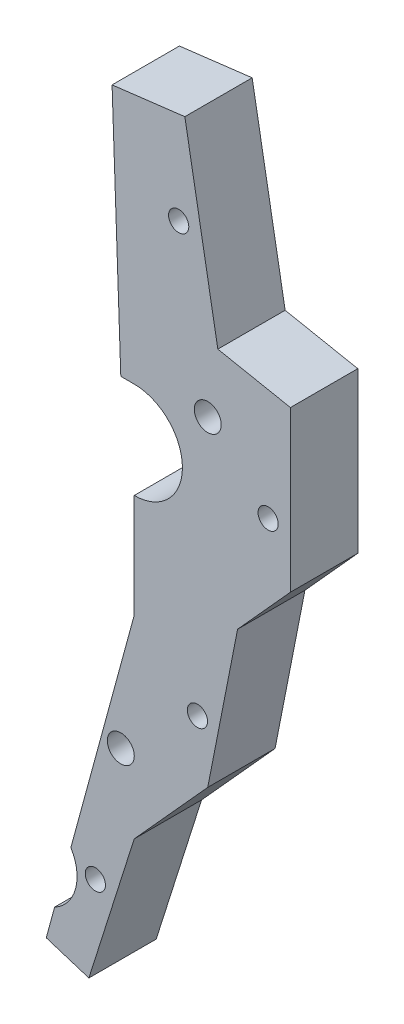
from build123d import *

# Parameters (mm, degrees)
SKETCH1_R           = 0.75
SKETCH1_R_2         = 1
BOSS_EXTRUDE1_DEPTH = 5
SKETCH2_R           = 3.161990297
CUT_EXTRUDE3_DEPTH  = 6


with BuildPart() as part:
    # Sketch1 → Boss-Extrude1 (new body)
    with BuildSketch(Plane.XY):
        with BuildLine():
            Line((-54.335741925, 25.84189954), (-51.886829877, 12.115657968))
            Line((-51.886829877, 12.115657968), (-46.495560397, 11.056658606))
            Line((-46.495560397, 11.056658606), (-46.495560397, -0.8192261))
            Line((-46.495560397, -0.8192261), (-50.419003961, -5.159962771))
            Line((-50.419003961, -5.159962771), (-52.634709942, -16.439920489))
            Line((-52.634709942, -16.439920489), (-58.094962161, -22.48091908))
            Line((-58.094962161, -22.48091908), (-61.461861486, -33.112780309))
            Line((-61.461861486, -33.112780309), (-64.627062483, -32.110424007))
            Line((-64.627062483, -32.110424007), (-58.094962161, -8.109055729))
            Line((-58.094962161, -8.109055729), (-58.094962161, -0.397611229))
            ThreePointArc((-58.094962161, -0.397611229), (-54.514396766, 3.182954166), (-58.094962161, 6.763519562))
            Line((-58.094962161, 6.763519562), (-59.090495064, 6.763519562))
            Line((-59.090495064, 6.763519562), (-59.738806897, 25.184479172))
            Line((-59.738806897, 25.184479172), (-54.335741925, 25.84189954))
        make_face()
        with Locations((-54.792818894, 18.90647511)):
            Circle(SKETCH1_R, mode=Mode.SUBTRACT)
        with Locations((-48.15, 3.1)):
            Circle(SKETCH1_R, mode=Mode.SUBTRACT)
        with Locations((-53.399319926, -12.218458076)):
            Circle(SKETCH1_R, mode=Mode.SUBTRACT)
        with Locations((-60.980346807, -26.52714596)):
            Circle(SKETCH1_R, mode=Mode.SUBTRACT)
        with Locations((-52.634709942, 7.375968546)):
            Circle(SKETCH1_R_2, mode=Mode.SUBTRACT)
        with Locations((-59.090495064, -17.158775628)):
            Circle(SKETCH1_R_2, mode=Mode.SUBTRACT)
    extrude(amount=BOSS_EXTRUDE1_DEPTH)

    # Sketch2 → Cut-Extrude3 (cut, through all)
    with BuildSketch(Plane.XY):
        with Locations((-65.5, -27.039327647)):
            Circle(SKETCH2_R)
    extrude(amount=CUT_EXTRUDE3_DEPTH, mode=Mode.SUBTRACT)


solid = part.part
